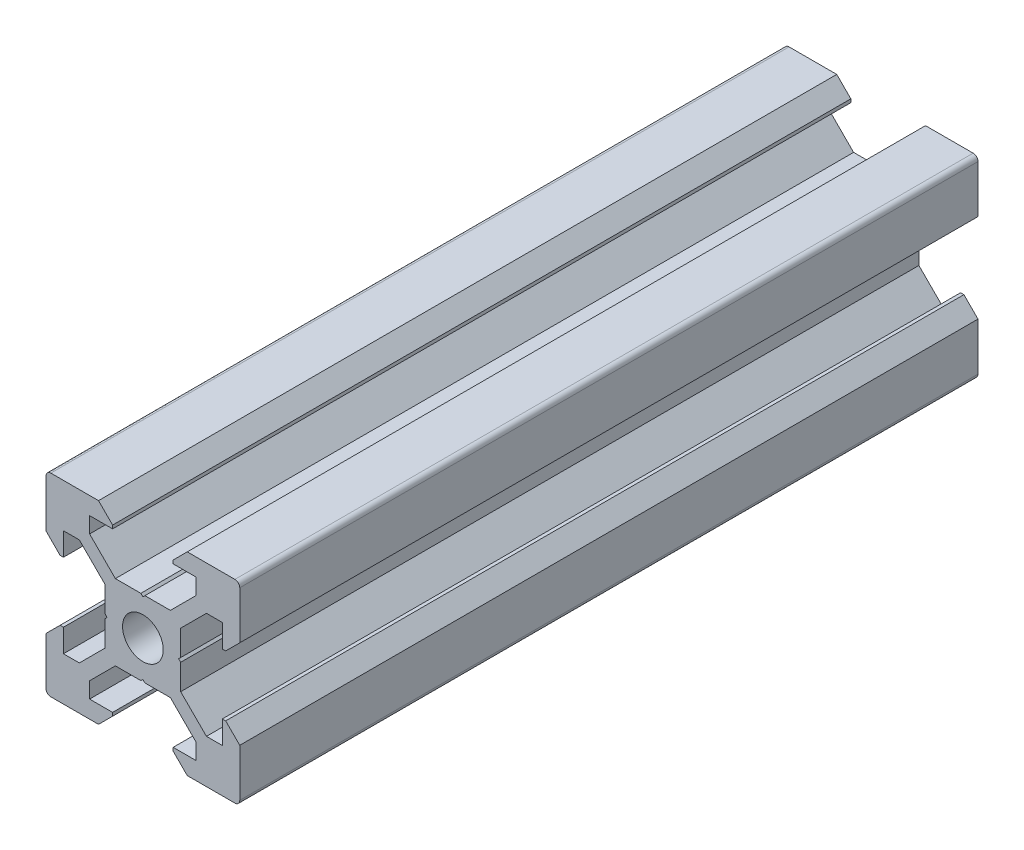
from build123d import *

# Parameters (mm, degrees)
SKETCH1_R           = 2.1
BOSS_EXTRUDE1_DEPTH = 76.2


with BuildPart() as part:
    # Sketch1 → Boss-Extrude1 (new body)
    with BuildSketch(Plane.XY):
        with BuildLine():
            Line((4.58, -10), (9.5, -10))
            ThreePointArc((9.5, -10), (9.853553391, -9.853553391), (10, -9.5))
            Line((10, -9.5), (10, -4.58))
            Line((10, -4.58), (8.545, -3.125))
            Line((8.545, -3.125), (8.2, -3.125))
            Line((8.2, -3.125), (8.2, -5.5))
            Line((8.2, -5.5), (6.560660172, -5.5))
            Line((6.560660172, -5.5), (3.9, -2.839339828))
            Line((3.9, -2.839339828), (3.9, -0.21))
            Line((3.9, -0.21), (3.69, 0))
            Line((3.69, 0), (3.9, 0.21))
            Line((3.9, 0.21), (3.9, 2.839339828))
            Line((3.9, 2.839339828), (6.560660172, 5.5))
            Line((6.560660172, 5.5), (8.2, 5.5))
            Line((8.2, 5.5), (8.2, 3.125))
            Line((8.2, 3.125), (8.545, 3.125))
            Line((8.545, 3.125), (10, 4.58))
            Line((10, 4.58), (10, 9.5))
            ThreePointArc((10, 9.5), (9.853553391, 9.853553391), (9.5, 10))
            Line((9.5, 10), (4.58, 10))
            Line((4.58, 10), (3.125, 8.545))
            Line((3.125, 8.545), (3.125, 8.2))
            Line((3.125, 8.2), (5.5, 8.2))
            Line((5.5, 8.2), (5.5, 6.560660172))
            Line((5.5, 6.560660172), (2.839339828, 3.9))
            Line((2.839339828, 3.9), (0.21, 3.9))
            Line((0.21, 3.9), (0, 3.69))
            Line((0, 3.69), (-0.21, 3.9))
            Line((-0.21, 3.9), (-2.839339828, 3.9))
            Line((-2.839339828, 3.9), (-5.5, 6.560660172))
            Line((-5.5, 6.560660172), (-5.5, 8.2))
            Line((-5.5, 8.2), (-3.125, 8.2))
            Line((-3.125, 8.2), (-3.125, 8.545))
            Line((-3.125, 8.545), (-4.58, 10))
            Line((-4.58, 10), (-9.5, 10))
            ThreePointArc((-9.5, 10), (-9.853553391, 9.853553391), (-10, 9.5))
            Line((-10, 9.5), (-10, 4.58))
            Line((-10, 4.58), (-8.545, 3.125))
            Line((-8.545, 3.125), (-8.2, 3.125))
            Line((-8.2, 3.125), (-8.2, 5.5))
            Line((-8.2, 5.5), (-6.560660172, 5.5))
            Line((-6.560660172, 5.5), (-3.9, 2.839339828))
            Line((-3.9, 2.839339828), (-3.9, 0.21))
            Line((-3.9, 0.21), (-3.69, 0))
            Line((-3.69, 0), (-3.9, -0.21))
            Line((-3.9, -0.21), (-3.9, -2.839339828))
            Line((-3.9, -2.839339828), (-6.560660172, -5.5))
            Line((-6.560660172, -5.5), (-8.2, -5.5))
            Line((-8.2, -5.5), (-8.2, -3.125))
            Line((-8.2, -3.125), (-8.545, -3.125))
            Line((-8.545, -3.125), (-10, -4.58))
            Line((-10, -4.58), (-10, -9.5))
            ThreePointArc((-10, -9.5), (-9.853553391, -9.853553391), (-9.5, -10))
            Line((-9.5, -10), (-4.58, -10))
            Line((-4.58, -10), (-3.125, -8.545))
            Line((-3.125, -8.545), (-3.125, -8.2))
            Line((-3.125, -8.2), (-5.5, -8.2))
            Line((-5.5, -8.2), (-5.5, -6.560660172))
            Line((-5.5, -6.560660172), (-2.839339828, -3.9))
            Line((-2.839339828, -3.9), (-0.21, -3.9))
            Line((-0.21, -3.9), (0, -3.69))
            Line((0, -3.69), (0.21, -3.9))
            Line((0.21, -3.9), (2.839339828, -3.9))
            Line((2.839339828, -3.9), (5.5, -6.560660172))
            Line((5.5, -6.560660172), (5.5, -8.2))
            Line((5.5, -8.2), (3.125, -8.2))
            Line((3.125, -8.2), (3.125, -8.545))
            Line((3.125, -8.545), (4.58, -10))
        make_face()
        Circle(SKETCH1_R, mode=Mode.SUBTRACT)
    extrude(amount=BOSS_EXTRUDE1_DEPTH)


solid = part.part
